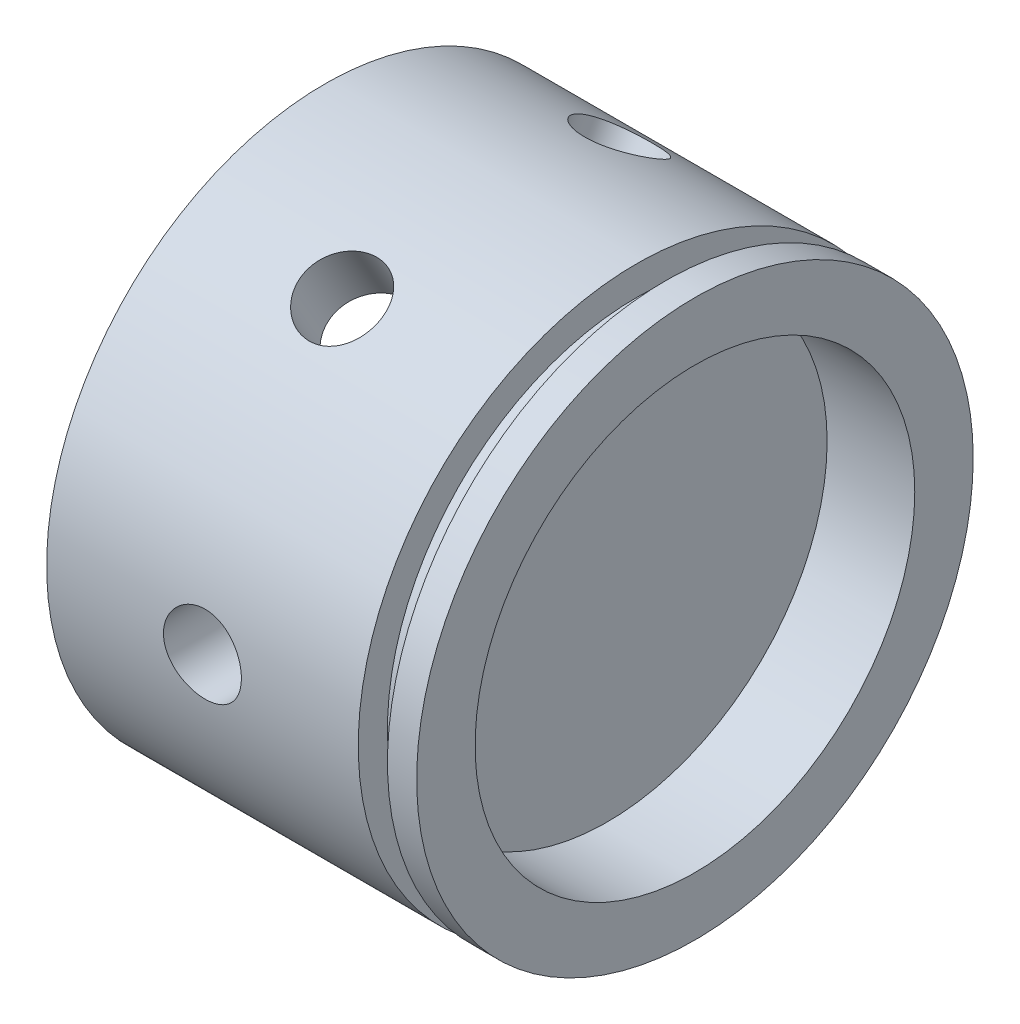
from build123d import *

# Parameters (mm, degrees)
ESBO_O2_R             = 4
CORTE_EXTRUS_O1_DEPTH = 60
PADR_OCIRCULAR1_COUNT = 6


with BuildPart() as part:
    # Esboço1 → Revolução1 (revolve)
    with BuildSketch(Plane.XY):
        Polygon((35, 28.575), (38, 28.575), (38, 22.575), (29, 22.575), (29, 0), (24, 0), (24, 22.575), (0, 22.575), (0, 28.575), (32, 28.575), (32, 25.575), (35, 25.575), align=None)
    revolve(axis=Axis((0, 0, 0), (-1, 0, 0)))

    # Esboço2 → Corte-extrusão1 (cut)
    with BuildSketch(Plane.XY):
        with Locations((16, 0)):
            Circle(ESBO_O2_R)
    corte_extrus_o1 = extrude(amount=-CORTE_EXTRUS_O1_DEPTH, mode=Mode.SUBTRACT)

    # PadrãoCircular1: Corte-extrusão1 ×6 about axis
    padr_ocircular1_axis = Axis((0, 0, 0), (1, 0, 0))
    for i in range(1, PADR_OCIRCULAR1_COUNT):
        add(corte_extrus_o1.rotate(padr_ocircular1_axis, i * 360 / PADR_OCIRCULAR1_COUNT), mode=Mode.SUBTRACT)


solid = part.part
